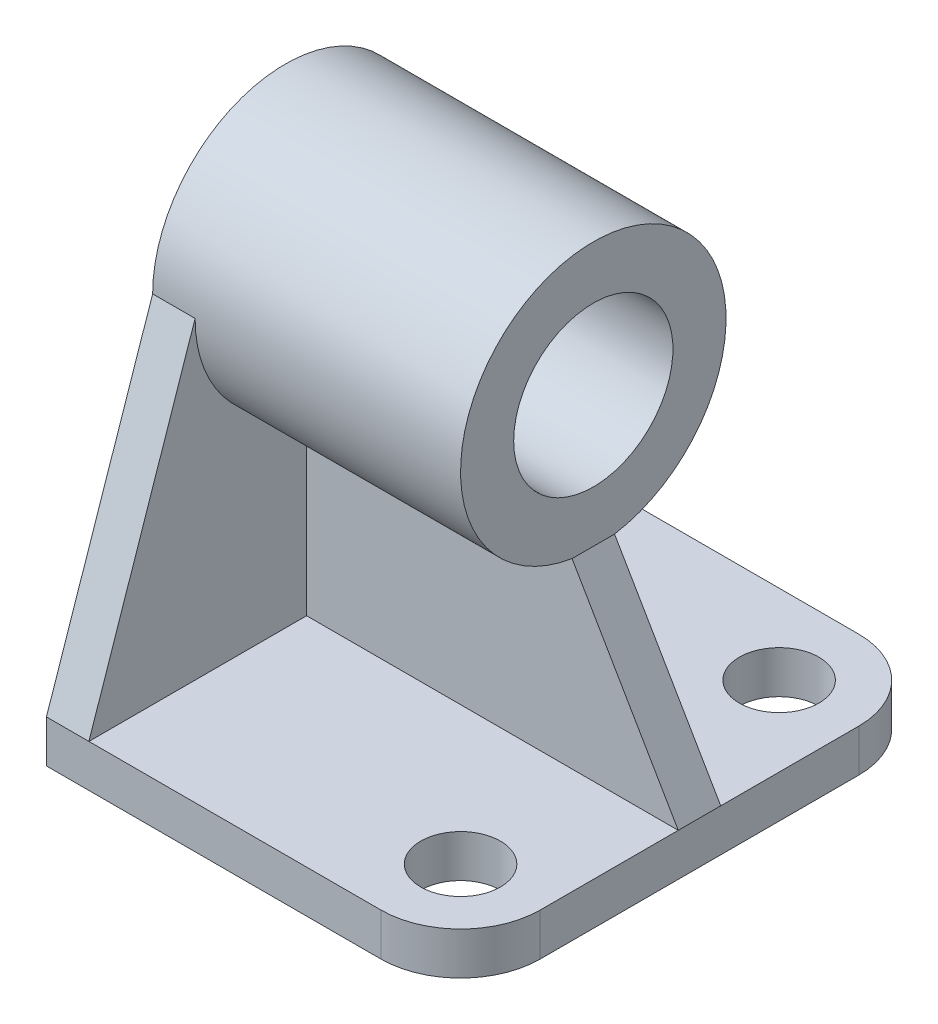
from build123d import *

# Parameters (mm, degrees)
SKETCH2_R           = 7.5
BOSS_EXTRUDE1_DEPTH = 8
BOSS_EXTRUDE3_DEPTH = 8
BOSS_EXTRUDE4_DEPTH = 58
SKETCH17_W          = 8
SKETCH17_H          = 39.501765498
BOSS_EXTRUDE6_DEPTH = 78
CUT_EXTRUDE1_DEPTH  = 78


with BuildPart() as part:
    # Sketch2 → Boss-Extrude1 (new body)
    with BuildSketch(Plane(origin=(0, 0, 0), x_dir=(1, 0, 0), z_dir=(0, 1, 0))):
        with BuildLine():
            Line((-4.545115865, -26.622255639), (58.454884135, -26.622255639))
            ThreePointArc((58.454884135, -26.622255639), (69.061485853, -22.228857357), (73.454884135, -11.622255639))
            Line((73.454884135, -11.622255639), (73.454884135, 48.377744361))
            ThreePointArc((73.454884135, 48.377744361), (69.061485853, 58.984346079), (58.454884135, 63.377744361))
            Line((58.454884135, 63.377744361), (-4.545115865, 63.377744361))
            Line((-4.545115865, 63.377744361), (-4.545115865, -26.622255639))
        make_face()
        with Locations((58.454884135, -11.622255639)):
            Circle(SKETCH2_R, mode=Mode.SUBTRACT)
        with Locations((58.454884135, 48.377744361)):
            Circle(SKETCH2_R, mode=Mode.SUBTRACT)
    extrude(amount=BOSS_EXTRUDE1_DEPTH)

    # Sketch3 → Boss-Extrude3 (add)
    with BuildSketch(Plane.ZY.offset(4.545115865)):
        with BuildLine():
            Line((-63.377744361, 8), (26.622255639, 8))
            Line((26.622255639, 8), (6.622255639, 67))
            ThreePointArc((6.622255639, 67), (-18.377744361, 42), (-43.377744361, 67))
            Line((-43.377744361, 67), (-63.377744361, 8))
        make_face()
    extrude(amount=-BOSS_EXTRUDE3_DEPTH)

    # Sketch3_4 → Boss-Extrude4 (add)
    with BuildSketch(Plane.ZY.offset(4.545115865)):
        with BuildLine():
            ThreePointArc((-43.377744361, 67), (-36.055413891, 49.32233047), (-18.377744361, 42))
            ThreePointArc((-18.377744361, 42), (-0.700074831, 49.32233047), (6.622255639, 67))
            ThreePointArc((6.622255639, 67), (-18.377744361, 92), (-43.377744361, 67))
        make_face()
        with BuildLine():
            ThreePointArc((-3.377744361, 67), (-7.771142643, 56.393398282), (-18.377744361, 52))
            ThreePointArc((-18.377744361, 52), (-28.984346079, 77.606601718), (-3.377744361, 67))
        make_face(mode=Mode.SUBTRACT)
    extrude(amount=-BOSS_EXTRUDE4_DEPTH)

    # Sketch17 → Boss-Extrude6 (add)
    with BuildSketch(Plane.ZY.offset(4.545115865)):
        with Locations((-18.377744361, 27.750882749)):
            Rectangle(SKETCH17_W, SKETCH17_H)
    extrude(amount=-BOSS_EXTRUDE6_DEPTH)

    # Sketch18 → Cut-Extrude1 (cut)
    with BuildSketch(Plane(origin=(0, 0, -22.377744361), x_dir=(-1, 0, 0), z_dir=(0, 0, -1))):
        Polygon((-73.454884135, 8), (-53.454884135, 42.322074641), (-53.454884135, 47.501765498), (-73.454884135, 47.501765498), align=None)
    extrude(amount=-CUT_EXTRUDE1_DEPTH, mode=Mode.SUBTRACT)


solid = part.part
